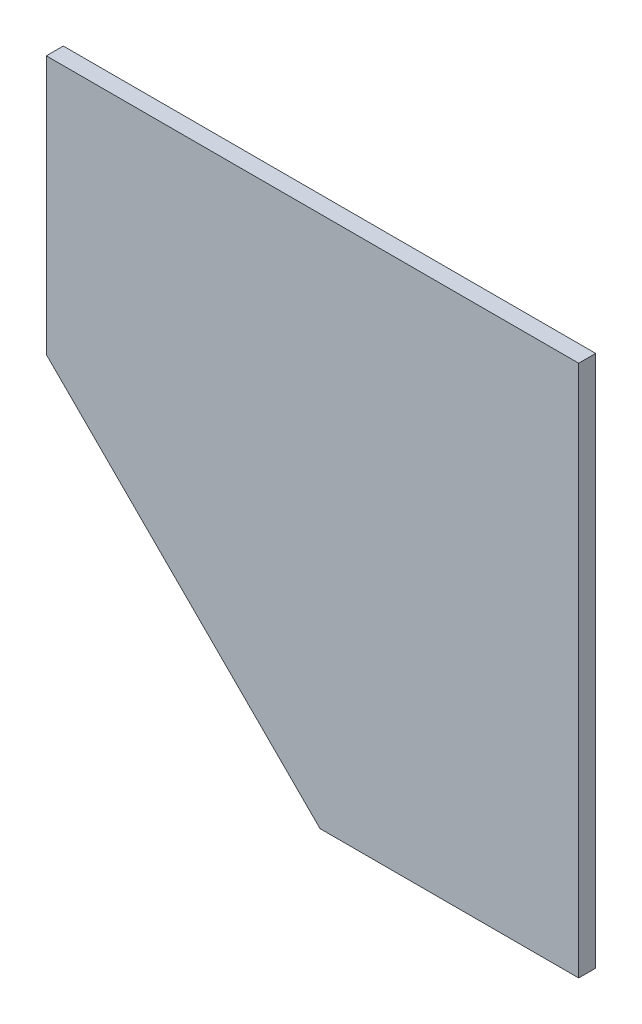
from build123d import *

# Parameters (mm, degrees)
BOSS_EXTRUDE1_DEPTH = 18


with BuildPart() as part:
    # Sketch1 → Boss-Extrude1 (new body)
    with BuildSketch(Plane.XY):
        Polygon((-282, -186.5), (8, -476.5), (282, -476.5), (282, 87.5), (-282, 87.5), align=None)
    extrude(amount=BOSS_EXTRUDE1_DEPTH)


solid = part.part
